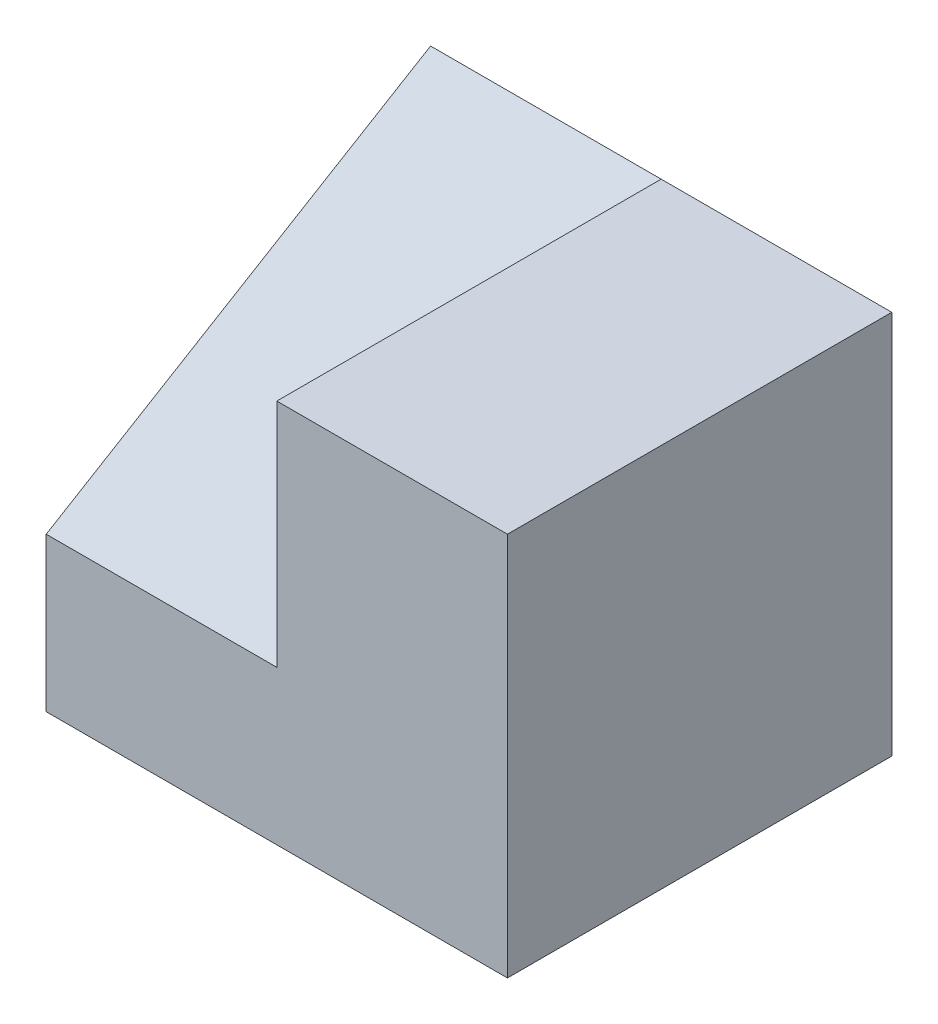
from build123d import *

# Parameters (mm, degrees)
BOSS_EXTRUDE1_DEPTH = 25
BOSS_EXTRUDE2_DEPTH = 15
SKETCH3_W           = 15
SKETCH3_H           = 15
CUT_EXTRUDE1_DEPTH  = 15


with BuildPart() as part:
    # Sketch1 → Boss-Extrude1 (new body)
    with BuildSketch(Plane.XY):
        Polygon((-30, 10), (-15, 10), (-15, 25), (0, 25), (0, 0), (-30, 0), align=None)
    extrude(amount=BOSS_EXTRUDE1_DEPTH)

    # Sketch2 → Boss-Extrude2 (add)
    with BuildSketch(Plane.ZY.offset(15)):
        Polygon((0, 25), (25, 10), (0, 10), align=None)
    extrude(amount=BOSS_EXTRUDE2_DEPTH)

    # Sketch3 → Cut-Extrude1 (cut)
    with BuildSketch(Plane(origin=(0, 0, 0), x_dir=(-1, 0, 0), z_dir=(0, 0, -1))):
        with Locations((22.5, 7.5)):
            Rectangle(SKETCH3_W, SKETCH3_H)
    extrude(amount=-CUT_EXTRUDE1_DEPTH, mode=Mode.SUBTRACT)


solid = part.part
